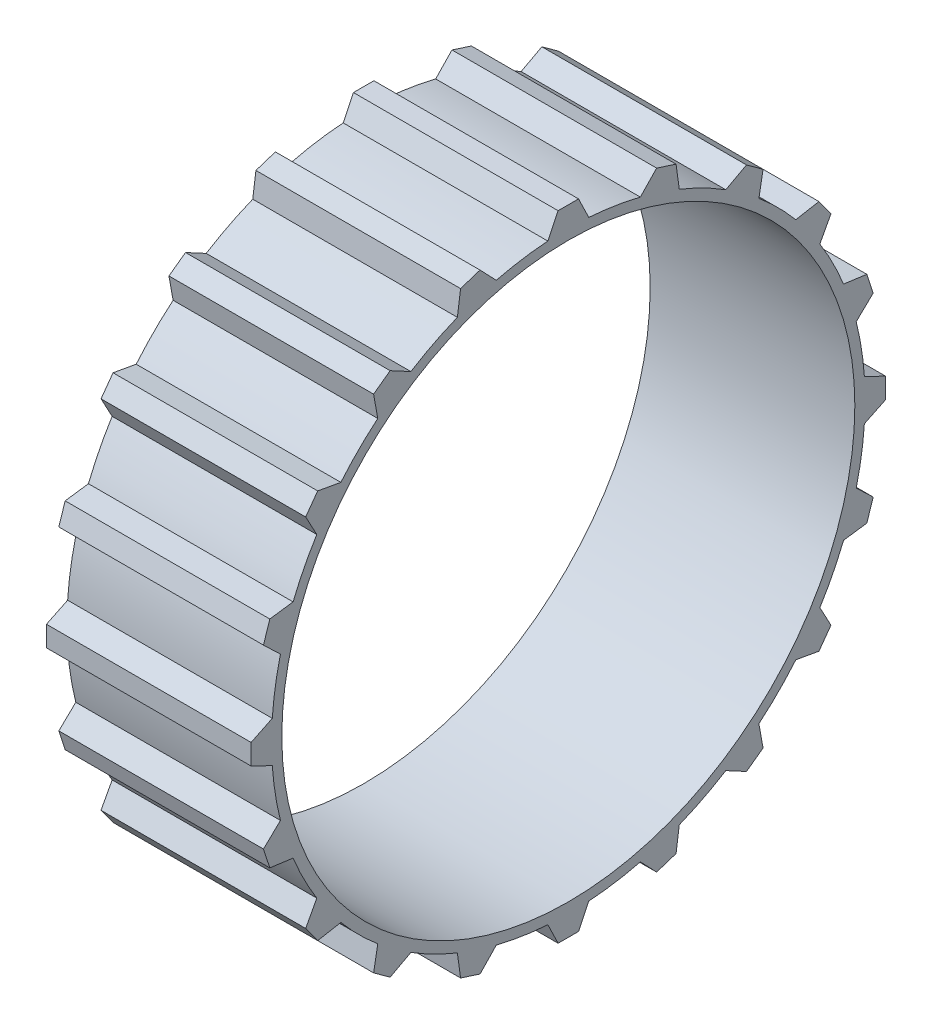
from build123d import *

# Parameters (mm, degrees)
SKETCH1_R           = 29
SKETCH1_R_2         = 28
BOSS_EXTRUDE1_DEPTH = 20
BOSS_EXTRUDE2_DEPTH = 20
CIRPATTERN1_COUNT   = 20


with BuildPart() as part:
    # Sketch1 → Boss-Extrude1 (new body)
    with BuildSketch(Plane(origin=(13.876749841, 0, 0), x_dir=(0, 0, -1), z_dir=(1, 0, 0))):
        with Locations((67.469370674, -50.661515593)):
            Circle(SKETCH1_R)
        with Locations((67.469370674, -50.661515593)):
            Circle(SKETCH1_R_2, mode=Mode.SUBTRACT)
    extrude(amount=-BOSS_EXTRUDE1_DEPTH)

    # Sketch2 → Boss-Extrude2 (add, through all)
    with BuildSketch(Plane(origin=(13.876749841, 0, 0), x_dir=(0, 0, -1), z_dir=(1, 0, 0))):
        with BuildLine():
            Line((66.469370674, -19.661515593), (65.469370674, -21.73056331))
            ThreePointArc((65.469370674, -21.73056331), (67.469370674, -21.661515593), (69.469370674, -21.73056331))
            Line((69.469370674, -21.73056331), (68.469370674, -19.661515593))
            Line((68.469370674, -19.661515593), (66.469370674, -19.661515593))
        make_face()
    boss_extrude2 = extrude(amount=-BOSS_EXTRUDE2_DEPTH)

    # CirPattern1: Boss-Extrude2 ×20 about axis
    cirpattern1_axis = Axis((0, -50.661515593, -67.469370674), (1, 0, 0))
    for i in range(1, CIRPATTERN1_COUNT):
        add(boss_extrude2.rotate(cirpattern1_axis, i * 360 / CIRPATTERN1_COUNT))


solid = part.part
